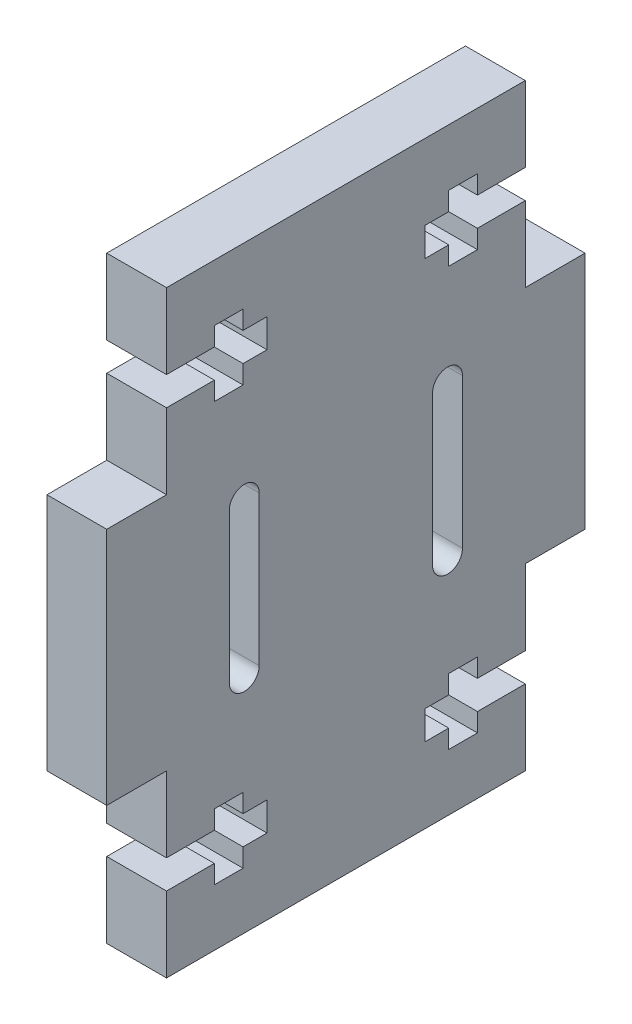
from build123d import *

# Parameters (mm, degrees)
BOSS_EXTRUDE1_DEPTH = 5
CUT_EXTRUDE1_DEPTH  = 6


with BuildPart() as part:
    # Sketch1 → Boss-Extrude1 (new body)
    with BuildSketch(Plane(origin=(0, 0, 0), x_dir=(0, 0, -1), z_dir=(1, 0, 0))):
        Polygon((-15, 50), (15, 50), (15, 35), (20, 35), (20, 15), (15, 15), (15, 0), (-15, 0), (-15, 15), (-20, 15), (-20, 35), (-15, 35), align=None)
        with BuildLine():
            Line((9.75, 31.25), (9.75, 18.75))
            ThreePointArc((9.75, 18.75), (8.5, 17.5), (7.25, 18.75))
            Line((7.25, 18.75), (7.25, 31.25))
            ThreePointArc((7.25, 31.25), (8.5, 32.5), (9.75, 31.25))
        make_face(mode=Mode.SUBTRACT)
        with BuildLine():
            Line((-9.75, 31.25), (-9.75, 18.75))
            ThreePointArc((-9.75, 18.75), (-8.5, 17.5), (-7.25, 18.75))
            Line((-7.25, 18.75), (-7.25, 31.25))
            ThreePointArc((-7.25, 31.25), (-8.5, 32.5), (-9.75, 31.25))
        make_face(mode=Mode.SUBTRACT)
    extrude(amount=BOSS_EXTRUDE1_DEPTH)

    # Sketch2 → Cut-Extrude1 (cut, through all)
    with BuildSketch(Plane(origin=(5, 0, 0), x_dir=(0, 0, -1), z_dir=(1, 0, 0))):
        Polygon((-15, 43.7), (-11, 43.7), (-11, 45.25), (-8.6, 45.25), (-8.6, 43.7), (-6.6, 43.7), (-6.6, 41.3), (-8.6, 41.3), (-8.6, 39.75), (-11, 39.75), (-11, 41.3), (-15, 41.3), align=None)
        Polygon((15, 41.3), (11, 41.3), (11, 39.75), (8.6, 39.75), (8.6, 41.3), (6.6, 41.3), (6.6, 43.7), (8.6, 43.7), (8.6, 45.25), (11, 45.25), (11, 43.7), (15, 43.7), align=None)
        Polygon((-15, 8.7), (-11, 8.7), (-11, 10.25), (-8.6, 10.25), (-8.6, 8.7), (-6.6, 8.7), (-6.6, 6.3), (-8.6, 6.3), (-8.6, 4.75), (-11, 4.75), (-11, 6.3), (-15, 6.3), align=None)
        Polygon((15, 6.3), (11, 6.3), (11, 4.75), (8.6, 4.75), (8.6, 6.3), (6.6, 6.3), (6.6, 8.7), (8.6, 8.7), (8.6, 10.25), (11, 10.25), (11, 8.7), (15, 8.7), align=None)
    extrude(amount=-CUT_EXTRUDE1_DEPTH, mode=Mode.SUBTRACT)


solid = part.part
